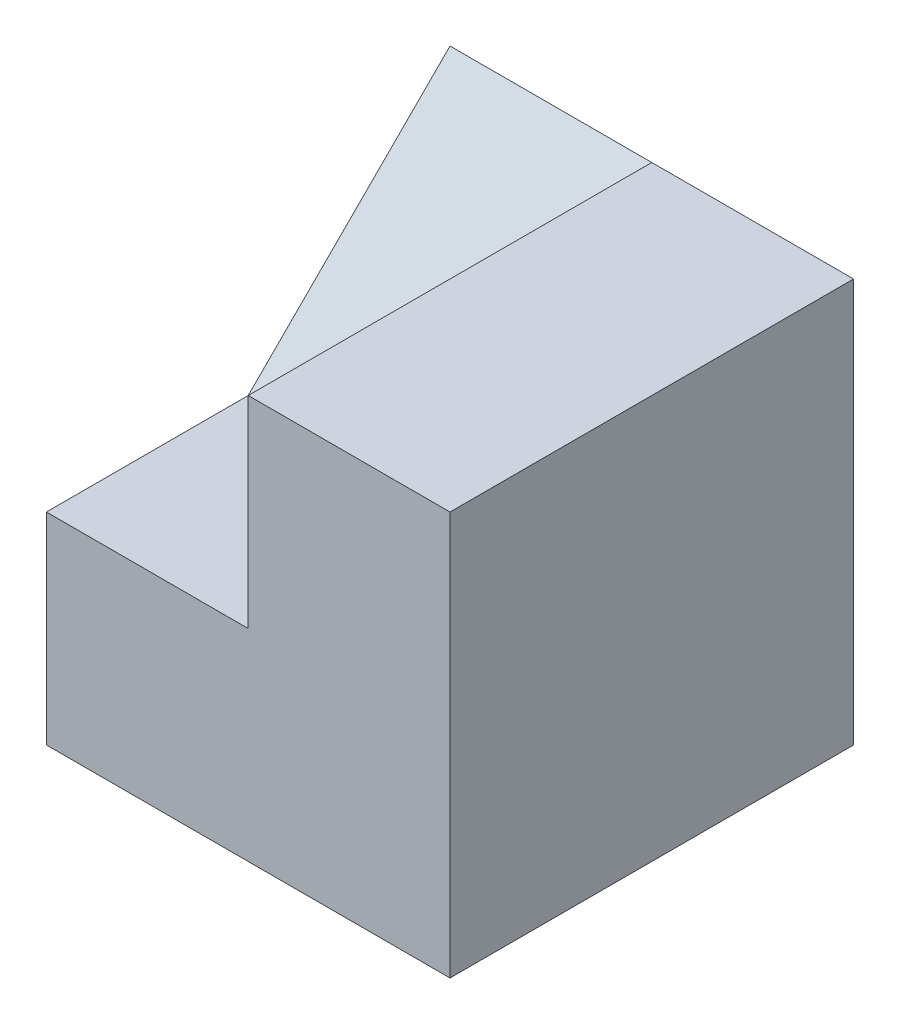
from build123d import *

# Parameters (mm, degrees)
SKETCH1_W           = 4
SKETCH1_H           = 4
BOSS_EXTRUDE1_DEPTH = 4
CUT_EXTRUDE1_DEPTH  = 2


with BuildPart() as part:
    # Sketch1 → Boss-Extrude1 (new body)
    with BuildSketch(Plane(origin=(0, 0, 0), x_dir=(1, 0, 0), z_dir=(0, 1, 0))):
        Rectangle(SKETCH1_W, SKETCH1_H)
    extrude(amount=BOSS_EXTRUDE1_DEPTH)

    # Sketch2 → Cut-Extrude1 (cut)
    with BuildSketch(Plane.ZY.offset(2)):
        Polygon((-2, 4), (0, 2), (2, 2), (2, 4), align=None)
    extrude(amount=-CUT_EXTRUDE1_DEPTH, mode=Mode.SUBTRACT)


solid = part.part
